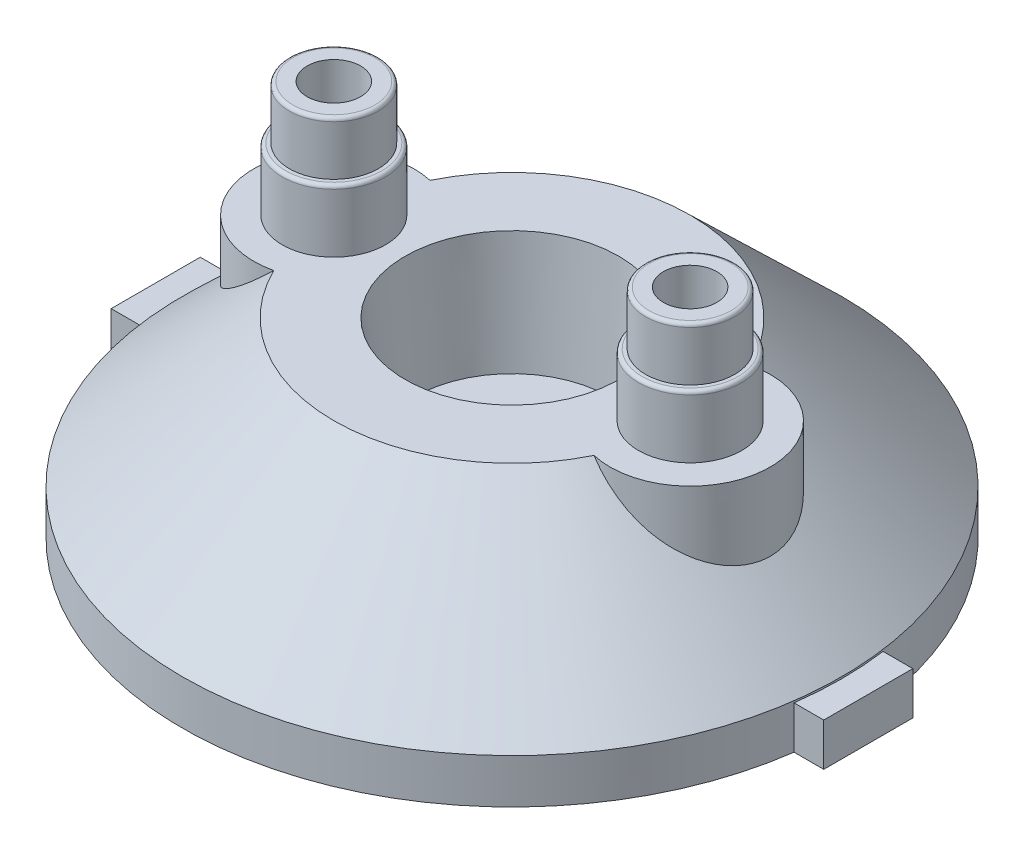
from build123d import *

# Parameters (mm, degrees)
SKETCH4_R            = 2.75
SKETCH4_R_2          = 1.5
BOSS_EXTRUDE2_DEPTH  = 3
CIRPATTERN1_COUNT    = 4
BOSS_EXTRUDE6_REACH  = 30.459
SKETCH6_R            = 2.9
BOSS_EXTRUDE7_DEPTH  = 3.5
SKETCH7_R            = 2.5
BOSS_EXTRUDE8_DEPTH  = 3
FILLET1_R            = 0.2
SKETCH8_R            = 1.5
CUT_EXTRUDE1_DEPTH   = 32.587814279
SKETCH9_R            = 3
CUT_EXTRUDE2_DEPTH   = 6.4
SKETCH10_W           = 3
SKETCH10_H           = 5
BOSS_EXTRUDE10_DEPTH = 2.4


with BuildPart() as part:
    # Sketch1 → Revolve1 (revolve)
    with BuildSketch(Plane.XY, mode=Mode.PRIVATE) as revolve1_sk:
        with BuildLine():
            Line((18.5, 0), (16.5, 0))
            Line((16.5, 0), (16.5, 2))
            Line((16.5, 2), (9.5, 9))
            Line((9.5, 9), (7.5, 9))
            Line((7.5, 9), (7.036020013, 3.061056166))
            ThreePointArc((7.036020013, 3.061056166), (6.877044526, 2.73293603), (6.537538942, 2.6))
            Line((6.537538942, 2.6), (2.5, 2.6))
            Line((2.5, 2.6), (2.5, 4.1))
            Line((2.5, 4.1), (5.5, 4.1))
            Line((5.5, 4.1), (6, 10.7))
            Line((6, 10.7), (10, 10.7))
            Line((10, 10.7), (18.5, 2.5))
            Line((18.5, 2.5), (18.5, 0))
        make_face()
    revolve(revolve1_sk.sketch.rotate(Axis((0, 0, 0), (0, 1, 0)), 90), axis=Axis((0, 0, 0), (0, 1, 0)))

    # Sketch4 → Boss-Extrude2 (add)
    with BuildSketch(Plane(origin=(0, -0.5, 0), x_dir=(1, 0, 0), z_dir=(0, 1, 0))):
        with Locations(Location((10.606601718, -10.606601718, 0), (0, 0, 28.495484479))):
            Circle(SKETCH4_R)
        with Locations(Location((10.606601718, -10.606601718, 0), (0, 0, 5.290983447))):
            Circle(SKETCH4_R_2, mode=Mode.SUBTRACT)
    boss_extrude2 = extrude(amount=BOSS_EXTRUDE2_DEPTH)

    # CirPattern1: Boss-Extrude2 ×4 about axis
    cirpattern1_axis = Axis((0, 0, 0), (0, 1, 0))
    for i in range(1, CIRPATTERN1_COUNT):
        add(boss_extrude2.rotate(cirpattern1_axis, i * 360 / CIRPATTERN1_COUNT))

    # Sketch5 → Boss-Extrude6 (add, up to next)
    with BuildSketch(Plane(origin=(0, 10.7, 0), x_dir=(1, 0, 0), z_dir=(0, 1, 0)), mode=Mode.PRIVATE) as boss_extrude6_sk1:
        with BuildLine():
            ThreePointArc((5.7875, -1.582669817), (14.5, 0), (5.7875, 1.582669817))
            ThreePointArc((5.7875, 1.582669817), (6, 0), (5.7875, -1.582669817))
        make_face()
    boss_extrude6_tool1 = extrude(boss_extrude6_sk1.sketch, amount=-BOSS_EXTRUDE6_REACH, mode=Mode.PRIVATE) - part.part
    # Sketch5 → Boss-Extrude6 (add, up to next)
    with BuildSketch(Plane(origin=(0, 10.7, 0), x_dir=(1, 0, 0), z_dir=(0, 1, 0)), mode=Mode.PRIVATE) as boss_extrude6_sk2:
        with BuildLine():
            ThreePointArc((-5.7875, -1.582669817), (-6, 0), (-5.7875, 1.582669817))
            ThreePointArc((-5.7875, 1.582669817), (-14.5, 0), (-5.7875, -1.582669817))
        make_face()
    boss_extrude6_tool2 = extrude(boss_extrude6_sk2.sketch, amount=-BOSS_EXTRUDE6_REACH, mode=Mode.PRIVATE) - part.part
    add(boss_extrude6_tool1.solids().sort_by_distance((10.071941, 10.7, 0))[0])
    add(boss_extrude6_tool2.solids().sort_by_distance((-10.071941, 10.7, 0))[0])

    # Sketch6 → Boss-Extrude7 (add)
    with BuildSketch(Plane(origin=(0, 10.7, 0), x_dir=(1, 0, 0), z_dir=(0, 1, 0))):
        with Locations(Location((10, 0, 0), (0, 0, 270))):
            Circle(SKETCH6_R)
        with Locations(Location((-10, 0, 0), (0, 0, 90))):
            Circle(SKETCH6_R)
    extrude(amount=BOSS_EXTRUDE7_DEPTH)

    # Sketch7 → Boss-Extrude8 (add)
    with BuildSketch(Plane(origin=(0, 14.2, 0), x_dir=(1, 0, 0), z_dir=(0, 1, 0))):
        with Locations(Location((10, 0, 0), (0, 0, 270))):
            Circle(SKETCH7_R)
        with Locations(Location((-10, 0, 0), (0, 0, 90))):
            Circle(SKETCH7_R)
    extrude(amount=BOSS_EXTRUDE8_DEPTH)

    # Fillet1
    fillet1_edges = [part.edges().sort_by_distance(p)[0] for p in [
        (10, 14.2, -2.9),
        (-10, 14.2, 2.9),
        (10, 17.2, -2.5),
        (-10, 17.2, 2.5),
    ]]
    fillet(fillet1_edges, radius=FILLET1_R)

    # Sketch8 → Cut-Extrude1 (cut, through all)
    with BuildSketch(Plane(origin=(0, 17.2, 0), x_dir=(1, 0, 0), z_dir=(0, 1, 0))):
        with Locations(Location((10, 0, 0), (0, 0, 270))):
            Circle(SKETCH8_R)
        with Locations(Location((-10, 0, 0), (0, 0, 293.578179424))):
            Circle(SKETCH8_R)
    extrude(amount=-CUT_EXTRUDE1_DEPTH, mode=Mode.SUBTRACT)

    # Sketch9 → Cut-Extrude2 (cut)
    with BuildSketch(Plane.XZ.offset(-2.6)):
        with Locations((10, 0)):
            Circle(SKETCH9_R)
    extrude(amount=-CUT_EXTRUDE2_DEPTH, mode=Mode.SUBTRACT)

    # Sketch10 → Boss-Extrude10 (add)
    with BuildSketch(Plane(origin=(0, 0, 0), x_dir=(1, 0, 0), z_dir=(0, 1, 0))):
        with Locations((18.5, 0)):
            Rectangle(SKETCH10_W, SKETCH10_H)
        with Locations((-18.5, 0)):
            Rectangle(SKETCH10_W, SKETCH10_H)
    extrude(amount=BOSS_EXTRUDE10_DEPTH)


solid = part.part
